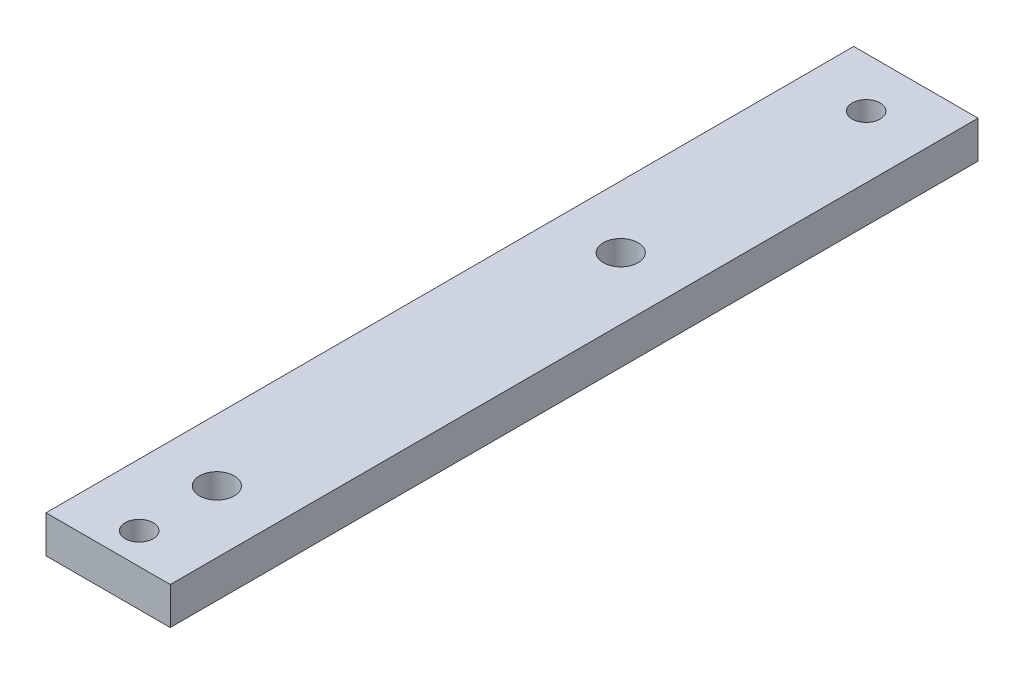
from build123d import *

# Parameters (mm, degrees)
SKETCH_1_W      = 10
SKETCH_1_H      = 65
SKETCH_1_R      = 1.4
SKETCH_1_R_2    = 1.125
EXTRUDE_1_DEPTH = 3


with BuildPart() as part:
    # 스케치1 → 보스-돌출1 (new body)
    with BuildSketch(Plane(origin=(0, 0, 0), x_dir=(1, 0, 0), z_dir=(0, 1, 0))):
        with Locations((-1.086956522, -18.043478261)):
            Rectangle(SKETCH_1_W, SKETCH_1_H)
        with Locations((-1.086956522, -9.293478261)):
            Circle(SKETCH_1_R, mode=Mode.SUBTRACT)
        with Locations((-1.086956522, -41.793478261)):
            Circle(SKETCH_1_R, mode=Mode.SUBTRACT)
        with Locations((-1.086956522, 10.456521739)):
            Circle(SKETCH_1_R_2, mode=Mode.SUBTRACT)
        with Locations((-1.086956522, -48.043478261)):
            Circle(SKETCH_1_R_2, mode=Mode.SUBTRACT)
    extrude(amount=EXTRUDE_1_DEPTH)


solid = part.part
